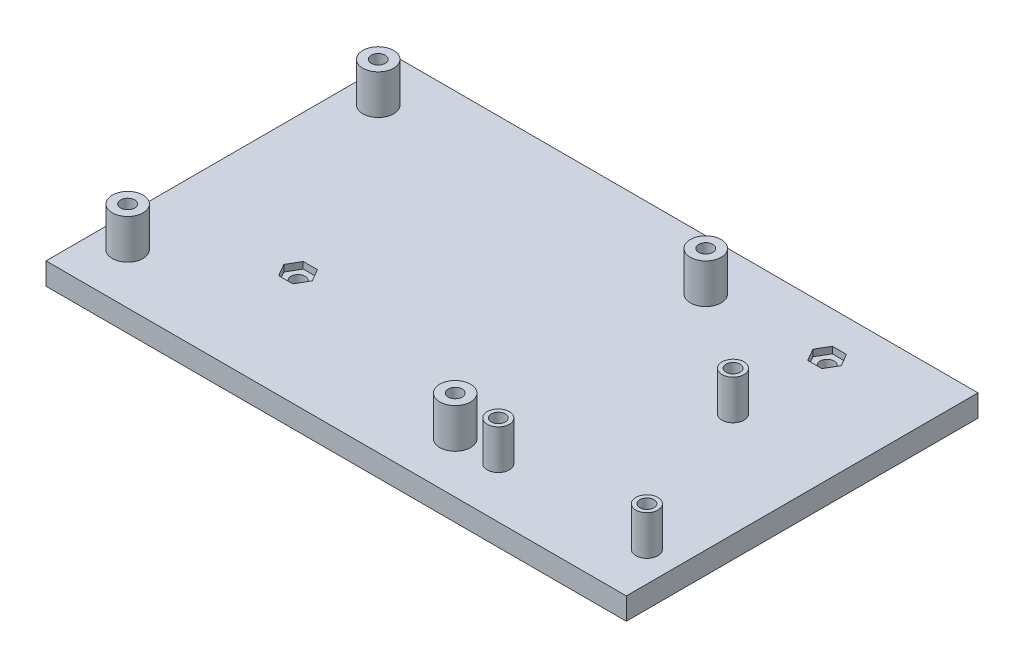
from build123d import *

# Parameters (mm, degrees)
SKETCH1_W                      = 132
SKETCH1_H                      = 80
BOSS_EXTRUDE1_DEPTH            = 5
SKETCH3_R                      = 3.5
SKETCH3_R_2                    = 2.5
BOSS_EXTRUDE2_DEPTH            = 9
CUT_EXTRUDE1_REACH             = 7
SKETCH2_R                      = 1.6
CUT_EXTRUDE1_DIRECTION_2_REACH = 11
SKETCH4_R                      = 3.05
CUT_EXTRUDE2_DEPTH             = 3.2
CUT_EXTRUDE3_REACH             = 7
SKETCH5_R                      = 1.6
CUT_EXTRUDE4_DEPTH             = 1.5


with BuildPart() as part:
    # Sketch1 → Boss-Extrude1 (new body)
    with BuildSketch(Plane(origin=(0, 0, 0), x_dir=(1, 0, 0), z_dir=(0, 1, 0))):
        Rectangle(SKETCH1_W, SKETCH1_H)
    extrude(amount=BOSS_EXTRUDE1_DEPTH)

    # Sketch3 → Boss-Extrude2 (add)
    with BuildSketch(Plane(origin=(0, 5, 0), x_dir=(1, 0, 0), z_dir=(0, 1, 0))):
        with Locations((-58.921474433, 28.5)):
            Circle(SKETCH3_R)
        with Locations((15.578525567, 28.5)):
            Circle(SKETCH3_R)
        with Locations((15.578525567, -28.5)):
            Circle(SKETCH3_R)
        with Locations((-58.921474433, -28.5)):
            Circle(SKETCH3_R)
        with Locations((25.378681006, -28.5)):
            Circle(SKETCH3_R_2)
        with Locations((59.178681006, -28.5)):
            Circle(SKETCH3_R_2)
        with Locations((42.278681006, 8)):
            Circle(SKETCH3_R_2)
    extrude(amount=BOSS_EXTRUDE2_DEPTH)

    # Sketch2 → Cut-Extrude1 (cut, up to next)
    with BuildSketch(Plane(origin=(0, 5, 0), x_dir=(1, 0, 0), z_dir=(0, 1, 0)), mode=Mode.PRIVATE) as cut_extrude1_sk1:
        with Locations((42.278681006, 8)):
            Circle(SKETCH2_R)
    cut_extrude1_tool1 = extrude(cut_extrude1_sk1.sketch, amount=-CUT_EXTRUDE1_REACH, mode=Mode.PRIVATE) & part.part
    add(cut_extrude1_tool1.solids().sort_by_distance((42.278681, 5, -8))[0], mode=Mode.SUBTRACT)
    # Sketch2 → Cut-Extrude1 (cut, up to next)
    with BuildSketch(Plane(origin=(0, 5, 0), x_dir=(1, 0, 0), z_dir=(0, 1, 0)), mode=Mode.PRIVATE) as cut_extrude1_sk2:
        with Locations((25.378681006, -28.5)):
            Circle(SKETCH2_R)
    cut_extrude1_tool2 = extrude(cut_extrude1_sk2.sketch, amount=-CUT_EXTRUDE1_REACH, mode=Mode.PRIVATE) & part.part
    add(cut_extrude1_tool2.solids().sort_by_distance((25.378681, 5, 28.5))[0], mode=Mode.SUBTRACT)
    # Sketch2 → Cut-Extrude1 (cut, up to next)
    with BuildSketch(Plane(origin=(0, 5, 0), x_dir=(1, 0, 0), z_dir=(0, 1, 0)), mode=Mode.PRIVATE) as cut_extrude1_sk3:
        with Locations((59.178681006, -28.5)):
            Circle(SKETCH2_R)
    cut_extrude1_tool3 = extrude(cut_extrude1_sk3.sketch, amount=-CUT_EXTRUDE1_REACH, mode=Mode.PRIVATE) & part.part
    add(cut_extrude1_tool3.solids().sort_by_distance((59.178681, 5, 28.5))[0], mode=Mode.SUBTRACT)
    # Sketch2 → Cut-Extrude1 (cut, up to next)
    with BuildSketch(Plane(origin=(0, 5, 0), x_dir=(1, 0, 0), z_dir=(0, 1, 0)), mode=Mode.PRIVATE) as cut_extrude1_sk4:
        with Locations((15.578525567, 28.5)):
            Circle(SKETCH2_R)
    cut_extrude1_tool4 = extrude(cut_extrude1_sk4.sketch, amount=-CUT_EXTRUDE1_REACH, mode=Mode.PRIVATE) & part.part
    add(cut_extrude1_tool4.solids().sort_by_distance((15.578526, 5, -28.5))[0], mode=Mode.SUBTRACT)
    # Sketch2 → Cut-Extrude1 (cut, up to next)
    with BuildSketch(Plane(origin=(0, 5, 0), x_dir=(1, 0, 0), z_dir=(0, 1, 0)), mode=Mode.PRIVATE) as cut_extrude1_sk5:
        with Locations((15.578525567, -28.5)):
            Circle(SKETCH2_R)
    cut_extrude1_tool5 = extrude(cut_extrude1_sk5.sketch, amount=-CUT_EXTRUDE1_REACH, mode=Mode.PRIVATE) & part.part
    add(cut_extrude1_tool5.solids().sort_by_distance((15.578526, 5, 28.5))[0], mode=Mode.SUBTRACT)
    # Sketch2 → Cut-Extrude1 (cut, up to next)
    with BuildSketch(Plane(origin=(0, 5, 0), x_dir=(1, 0, 0), z_dir=(0, 1, 0)), mode=Mode.PRIVATE) as cut_extrude1_sk6:
        with Locations((-58.921474433, -28.5)):
            Circle(SKETCH2_R)
    cut_extrude1_tool6 = extrude(cut_extrude1_sk6.sketch, amount=-CUT_EXTRUDE1_REACH, mode=Mode.PRIVATE) & part.part
    add(cut_extrude1_tool6.solids().sort_by_distance((-58.921474, 5, 28.5))[0], mode=Mode.SUBTRACT)
    # Sketch2 → Cut-Extrude1 (cut, up to next)
    with BuildSketch(Plane(origin=(0, 5, 0), x_dir=(1, 0, 0), z_dir=(0, 1, 0)), mode=Mode.PRIVATE) as cut_extrude1_sk7:
        with Locations((-58.921474433, 28.5)):
            Circle(SKETCH2_R)
    cut_extrude1_tool7 = extrude(cut_extrude1_sk7.sketch, amount=-CUT_EXTRUDE1_REACH, mode=Mode.PRIVATE) & part.part
    add(cut_extrude1_tool7.solids().sort_by_distance((-58.921474, 5, -28.5))[0], mode=Mode.SUBTRACT)

    # Sketch2 → Cut-Extrude1 direction 2 (cut, up to next)
    with BuildSketch(Plane(origin=(0, 5, 0), x_dir=(1, 0, 0), z_dir=(0, 1, 0)), mode=Mode.PRIVATE) as cut_extrude1_direction_2_sk1:
        with Locations((42.278681006, 8)):
            Circle(SKETCH2_R)
    cut_extrude1_direction_2_tool1 = extrude(cut_extrude1_direction_2_sk1.sketch, amount=CUT_EXTRUDE1_DIRECTION_2_REACH, mode=Mode.PRIVATE) & part.part
    add(cut_extrude1_direction_2_tool1.solids().sort_by_distance((42.278681, 5, -8))[0], mode=Mode.SUBTRACT)
    # Sketch2 → Cut-Extrude1 direction 2 (cut, up to next)
    with BuildSketch(Plane(origin=(0, 5, 0), x_dir=(1, 0, 0), z_dir=(0, 1, 0)), mode=Mode.PRIVATE) as cut_extrude1_direction_2_sk2:
        with Locations((25.378681006, -28.5)):
            Circle(SKETCH2_R)
    cut_extrude1_direction_2_tool2 = extrude(cut_extrude1_direction_2_sk2.sketch, amount=CUT_EXTRUDE1_DIRECTION_2_REACH, mode=Mode.PRIVATE) & part.part
    add(cut_extrude1_direction_2_tool2.solids().sort_by_distance((25.378681, 5, 28.5))[0], mode=Mode.SUBTRACT)
    # Sketch2 → Cut-Extrude1 direction 2 (cut, up to next)
    with BuildSketch(Plane(origin=(0, 5, 0), x_dir=(1, 0, 0), z_dir=(0, 1, 0)), mode=Mode.PRIVATE) as cut_extrude1_direction_2_sk3:
        with Locations((59.178681006, -28.5)):
            Circle(SKETCH2_R)
    cut_extrude1_direction_2_tool3 = extrude(cut_extrude1_direction_2_sk3.sketch, amount=CUT_EXTRUDE1_DIRECTION_2_REACH, mode=Mode.PRIVATE) & part.part
    add(cut_extrude1_direction_2_tool3.solids().sort_by_distance((59.178681, 5, 28.5))[0], mode=Mode.SUBTRACT)
    # Sketch2 → Cut-Extrude1 direction 2 (cut, up to next)
    with BuildSketch(Plane(origin=(0, 5, 0), x_dir=(1, 0, 0), z_dir=(0, 1, 0)), mode=Mode.PRIVATE) as cut_extrude1_direction_2_sk4:
        with Locations((15.578525567, 28.5)):
            Circle(SKETCH2_R)
    cut_extrude1_direction_2_tool4 = extrude(cut_extrude1_direction_2_sk4.sketch, amount=CUT_EXTRUDE1_DIRECTION_2_REACH, mode=Mode.PRIVATE) & part.part
    add(cut_extrude1_direction_2_tool4.solids().sort_by_distance((15.578526, 5, -28.5))[0], mode=Mode.SUBTRACT)
    # Sketch2 → Cut-Extrude1 direction 2 (cut, up to next)
    with BuildSketch(Plane(origin=(0, 5, 0), x_dir=(1, 0, 0), z_dir=(0, 1, 0)), mode=Mode.PRIVATE) as cut_extrude1_direction_2_sk5:
        with Locations((15.578525567, -28.5)):
            Circle(SKETCH2_R)
    cut_extrude1_direction_2_tool5 = extrude(cut_extrude1_direction_2_sk5.sketch, amount=CUT_EXTRUDE1_DIRECTION_2_REACH, mode=Mode.PRIVATE) & part.part
    add(cut_extrude1_direction_2_tool5.solids().sort_by_distance((15.578526, 5, 28.5))[0], mode=Mode.SUBTRACT)
    # Sketch2 → Cut-Extrude1 direction 2 (cut, up to next)
    with BuildSketch(Plane(origin=(0, 5, 0), x_dir=(1, 0, 0), z_dir=(0, 1, 0)), mode=Mode.PRIVATE) as cut_extrude1_direction_2_sk6:
        with Locations((-58.921474433, -28.5)):
            Circle(SKETCH2_R)
    cut_extrude1_direction_2_tool6 = extrude(cut_extrude1_direction_2_sk6.sketch, amount=CUT_EXTRUDE1_DIRECTION_2_REACH, mode=Mode.PRIVATE) & part.part
    add(cut_extrude1_direction_2_tool6.solids().sort_by_distance((-58.921474, 5, 28.5))[0], mode=Mode.SUBTRACT)
    # Sketch2 → Cut-Extrude1 direction 2 (cut, up to next)
    with BuildSketch(Plane(origin=(0, 5, 0), x_dir=(1, 0, 0), z_dir=(0, 1, 0)), mode=Mode.PRIVATE) as cut_extrude1_direction_2_sk7:
        with Locations((-58.921474433, 28.5)):
            Circle(SKETCH2_R)
    cut_extrude1_direction_2_tool7 = extrude(cut_extrude1_direction_2_sk7.sketch, amount=CUT_EXTRUDE1_DIRECTION_2_REACH, mode=Mode.PRIVATE) & part.part
    add(cut_extrude1_direction_2_tool7.solids().sort_by_distance((-58.921474, 5, -28.5))[0], mode=Mode.SUBTRACT)

    # Sketch4 → Cut-Extrude2 (cut)
    with BuildSketch(Plane.XZ):
        with Locations((42.278681006, -8)):
            Circle(SKETCH4_R)
        with Locations((59.178681006, 28.5)):
            Circle(SKETCH4_R)
        with Locations((25.378681006, 28.5)):
            Circle(SKETCH4_R)
        with Locations((15.578525567, 28.5)):
            Circle(SKETCH4_R)
        with Locations((15.578525567, -28.5)):
            Circle(SKETCH4_R)
        with Locations((-58.921474433, -28.5)):
            Circle(SKETCH4_R)
        with Locations((-58.921474433, 28.5)):
            Circle(SKETCH4_R)
    extrude(amount=-CUT_EXTRUDE2_DEPTH, mode=Mode.SUBTRACT)

    # Sketch5 → Cut-Extrude3 (cut, up to next)
    with BuildSketch(Plane(origin=(0, 5, 0), x_dir=(1, 0, 0), z_dir=(0, 1, 0)), mode=Mode.PRIVATE) as cut_extrude3_sk1:
        with Locations((-35.011855655, -13.657285002)):
            Circle(SKETCH5_R)
    cut_extrude3_tool1 = extrude(cut_extrude3_sk1.sketch, amount=-CUT_EXTRUDE3_REACH, mode=Mode.PRIVATE) & part.part
    add(cut_extrude3_tool1.solids().sort_by_distance((-35.011856, 5, 13.657285))[0], mode=Mode.SUBTRACT)
    # Sketch5 → Cut-Extrude3 (cut, up to next)
    with BuildSketch(Plane(origin=(0, 5, 0), x_dir=(1, 0, 0), z_dir=(0, 1, 0)), mode=Mode.PRIVATE) as cut_extrude3_sk2:
        with Locations((41.861471436, 29.814909243)):
            Circle(SKETCH5_R)
    cut_extrude3_tool2 = extrude(cut_extrude3_sk2.sketch, amount=-CUT_EXTRUDE3_REACH, mode=Mode.PRIVATE) & part.part
    add(cut_extrude3_tool2.solids().sort_by_distance((41.861471, 5, -29.814909))[0], mode=Mode.SUBTRACT)

    # Sketch6 → Cut-Extrude4 (cut)
    with BuildSketch(Plane(origin=(0, 5, 0), x_dir=(1, 0, 0), z_dir=(0, 1, 0))):
        Polygon((-33.395274901, -16.457285002), (-31.778694147, -13.657285002), (-33.395274901, -10.857285002), (-36.628436408, -10.857285002), (-38.245017162, -13.657285002), (-36.628436408, -16.457285002), align=None)
        Polygon((43.478052189, 27.014909243), (45.094632943, 29.814909243), (43.478052189, 32.614909243), (40.244890682, 32.614909243), (38.628309928, 29.814909243), (40.244890682, 27.014909243), align=None)
    extrude(amount=-CUT_EXTRUDE4_DEPTH, mode=Mode.SUBTRACT)


solid = part.part
